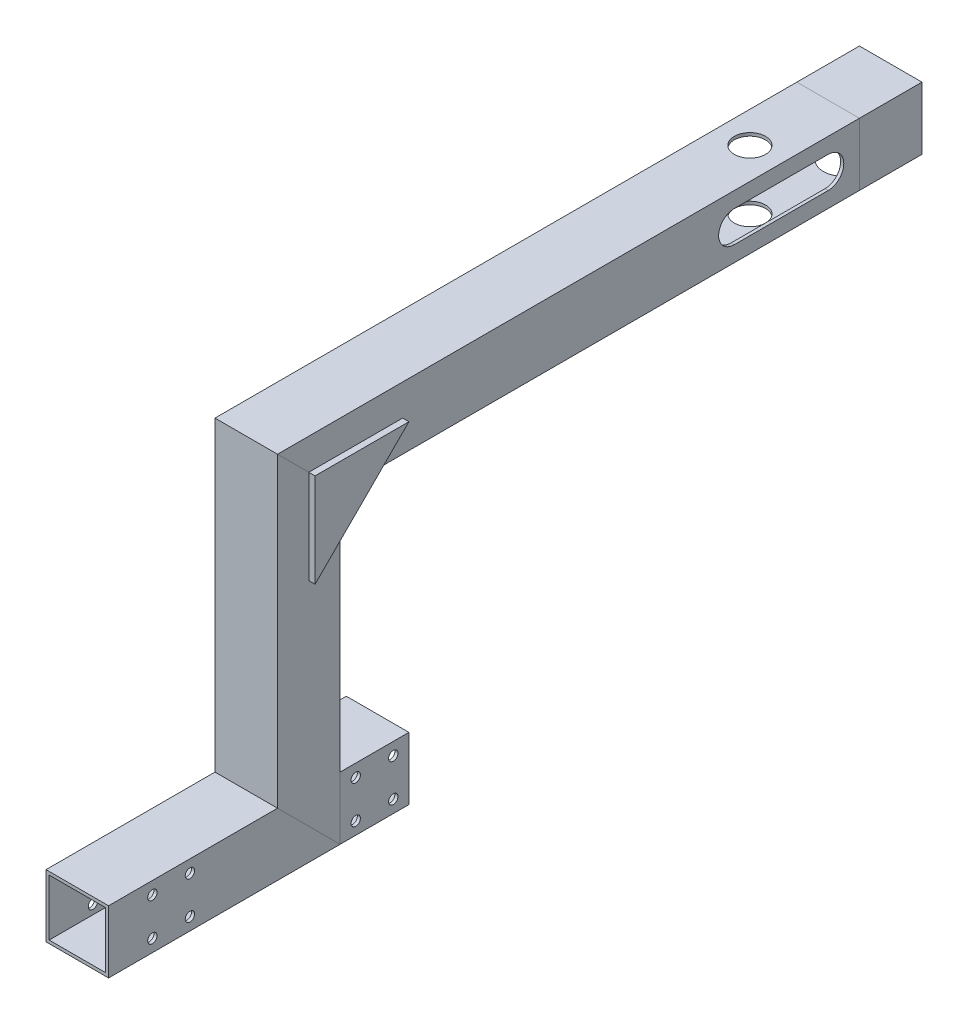
from build123d import *

# Parameters (mm, degrees)
SKETCH_14_W                = 20
SKETCH_14_H                = 20
SKETCH_14_W_2              = 18
SKETCH_14_H_2              = 18
F_20X20X1_1_DEPTH          = 79.142135624
SKETCH_14_ON_SEGMENT_2_W   = 20
SKETCH_14_ON_SEGMENT_2_H   = 20
SKETCH_14_ON_SEGMENT_2_W_2 = 18
SKETCH_14_ON_SEGMENT_2_H_2 = 18
F_20X20X1_1_2_DEPTH        = 128.284271247
SKETCH_14_ON_SEGMENT_3_W   = 20
SKETCH_14_ON_SEGMENT_3_H   = 20
SKETCH_14_ON_SEGMENT_3_W_2 = 18
SKETCH_14_ON_SEGMENT_3_H_2 = 18
F_20X20X1_1_3_DEPTH        = 191.142135624
SKETCH_14_ON_SEGMENT_4_W   = 20
SKETCH_14_ON_SEGMENT_4_H   = 20
SKETCH_14_ON_SEGMENT_4_W_2 = 18
SKETCH_14_ON_SEGMENT_4_H_2 = 18
F_20X20X1_1_4_DEPTH        = 62
SKETCH_12_R                = 1.5
CUT_EXTRUDE_1_DEPTH        = 264.939386981
CUT_EXTRUDE_3_DEPTH        = 264.939386981
CUT_EXTRUDE_4_DEPTH        = 260.43014474
EXTRUDE_1_DEPTH            = 2
EXTRUDE_2_DEPTH            = 2
SKETCH_25_W                = 20
SKETCH_25_H                = 20
SKETCH_25_W_2              = 18
SKETCH_25_H_2              = 18
EXTRUDE_3_DEPTH            = 20
SKETCH_26_R                = 6.5
CUT_EXTRUDE_9_DEPTH        = 1
SKETCH_27_R                = 1.5
CUT_EXTRUDE_10_DEPTH       = 1
SKETCH_17_R                = 1.5
CUT_EXTRUDE_11_DEPTH       = 283.396883835
SKETCH_28_W                = 29
SKETCH_28_H                = 20
CUT_EXTRUDE_12_DEPTH       = 283.396883835


with BuildPart() as part:
    # 草图14 → 铝管 20X20X1(1) (new body)
    with BuildSketch(Plane.YX):
        Rectangle(SKETCH_14_W, SKETCH_14_H)
        Rectangle(SKETCH_14_W_2, SKETCH_14_H_2, mode=Mode.SUBTRACT)
    extrude(amount=F_20X20X1_1_DEPTH)

    # 铝管 20X20X1(1) mitre 1
    split(bisect_by=Plane(origin=(0, 0, -64), x_dir=(1, 0, 0), z_dir=(0, -0.707106781, 0.707106781)), keep=Keep.TOP)

    # 草图12 → 切除-拉伸1 (cut, through all)
    with BuildSketch(Plane(origin=(10, 0, 0), x_dir=(0, 0, -1), z_dir=(1, 0, 0))):
        with Locations((14, 6)):
            Circle(SKETCH_12_R)
        with Locations((14, -6)):
            Circle(SKETCH_12_R)
        with Locations((26, -6)):
            Circle(SKETCH_12_R)
        with Locations((26, 6)):
            Circle(SKETCH_12_R)
    extrude(amount=-CUT_EXTRUDE_1_DEPTH, mode=Mode.SUBTRACT)


with BuildPart() as body_2:
    # 草图14 on segment 2 (carried to segment 2) → 20X20X1_1 2 (new body)
    with BuildSketch(Plane(origin=(0, -15.142135624, -64), x_dir=(0, 0, 1), z_dir=(0, 1, 0))):
        Rectangle(SKETCH_14_ON_SEGMENT_2_W, SKETCH_14_ON_SEGMENT_2_H)
        Rectangle(SKETCH_14_ON_SEGMENT_2_W_2, SKETCH_14_ON_SEGMENT_2_H_2, mode=Mode.SUBTRACT)
    extrude(amount=F_20X20X1_1_2_DEPTH)

    # 20X20X1_1 2 mitre 1
    split(bisect_by=Plane(origin=(0, 0, -64), x_dir=(-1, 0, 0), z_dir=(0, 0.707106781, -0.707106781)), keep=Keep.TOP)

    # 20X20X1_1 2 mitre 2
    split(bisect_by=Plane(origin=(0, 98, -64), x_dir=(1, 0, 0), z_dir=(0, -0.707106781, 0.707106781)), keep=Keep.TOP)


with BuildPart() as body_3:
    # 草图14 on segment 3 (carried to segment 3) → 20X20X1_1 3 (new body)
    with BuildSketch(Plane(origin=(0, 98, -48.857864376), x_dir=(0, 1, 0), z_dir=(0, 0, -1))):
        Rectangle(SKETCH_14_ON_SEGMENT_3_W, SKETCH_14_ON_SEGMENT_3_H)
        Rectangle(SKETCH_14_ON_SEGMENT_3_W_2, SKETCH_14_ON_SEGMENT_3_H_2, mode=Mode.SUBTRACT)
    extrude(amount=F_20X20X1_1_3_DEPTH)

    # 20X20X1_1 3 mitre 1
    split(bisect_by=Plane(origin=(0, 98, -64), x_dir=(-1, 0, 0), z_dir=(0, 0.707106781, -0.707106781)), keep=Keep.TOP)

    # 草图15 → 切除-拉伸3 (cut, through all)
    with BuildSketch(Plane(origin=(10, 0, 0), x_dir=(0, 0, -1), z_dir=(1, 0, 0))):
        with BuildLine():
            Line((200, 103), (230, 103))
            ThreePointArc((230, 103), (235, 98), (230, 93))
            Line((230, 93), (200, 93))
            ThreePointArc((200, 93), (195, 98), (200, 103))
        make_face()
    extrude(amount=-CUT_EXTRUDE_3_DEPTH, mode=Mode.SUBTRACT)

    # 草图16 → 切除-拉伸4 (cut, through all)
    with BuildSketch(Plane.XZ.offset(-88)):
        with BuildLine():
            ThreePointArc((-5, -215), (0, -220), (5, -215))
            Line((5, -215), (-5, -215))
        make_face()
        with BuildLine():
            Line((-5, -215), (5, -215))
            ThreePointArc((5, -215), (0, -210), (-5, -215))
        make_face()
    extrude(amount=-CUT_EXTRUDE_4_DEPTH, mode=Mode.SUBTRACT)


with BuildPart() as body_4:
    # 草图14 on segment 4 (carried to segment 4) → 20X20X1_1 4 (new body)
    with BuildSketch(Plane.YX.offset(63)):
        Rectangle(SKETCH_14_ON_SEGMENT_4_W, SKETCH_14_ON_SEGMENT_4_H)
        Rectangle(SKETCH_14_ON_SEGMENT_4_W_2, SKETCH_14_ON_SEGMENT_4_H_2, mode=Mode.SUBTRACT)
    extrude(amount=F_20X20X1_1_4_DEPTH)

    # 20X20X1_1 4 mitre 1
    split(bisect_by=Plane.YX.offset(74), keep=Keep.TOP)

    # 草图17 → 切除-拉伸11 (cut, through all)
    with BuildSketch(Plane(origin=(10, 0, 0), x_dir=(0, 0, -1), z_dir=(1, 0, 0))):
        with Locations((79, 6)):
            Circle(SKETCH_17_R)
        with Locations((79, -6)):
            Circle(SKETCH_17_R)
        with Locations((91, -6)):
            Circle(SKETCH_17_R)
        with Locations((91, 6)):
            Circle(SKETCH_17_R)
    extrude(amount=-CUT_EXTRUDE_11_DEPTH, mode=Mode.SUBTRACT)

    # 草图28 → 切除-拉伸12 (cut, through all)
    with BuildSketch(Plane(origin=(10, 0, 0), x_dir=(0, 0, -1), z_dir=(1, 0, 0))):
        with Locations((110.5, 0)):
            Rectangle(SKETCH_28_W, SKETCH_28_H)
    extrude(amount=-CUT_EXTRUDE_12_DEPTH, mode=Mode.SUBTRACT)


with BuildPart() as body_5:
    # 草图22 → 凸台-拉伸1 (new body)
    with BuildSketch(Plane(origin=(10, 0, 0), x_dir=(0, 0, -1), z_dir=(1, 0, 0))):
        Polygon((64, 98), (64, 68), (94, 98), align=None)
    extrude(amount=EXTRUDE_1_DEPTH)


with BuildPart() as body_6:
    # 草图23 → 凸台-拉伸2 (new body)
    with BuildSketch(Plane.ZY.offset(10)):
        Polygon((-64, 98), (-94, 98), (-64, 68), align=None)
    extrude(amount=EXTRUDE_2_DEPTH)


with BuildPart() as body_7:
    # 草图25 → 凸台-拉伸3 (new body)
    with BuildSketch(Plane(origin=(0, 0, -240), x_dir=(-1, 0, 0), z_dir=(0, 0, -1))):
        with Locations((0, 98)):
            Rectangle(SKETCH_25_W, SKETCH_25_H)
        with Locations((0, 98)):
            Rectangle(SKETCH_25_W_2, SKETCH_25_H_2, mode=Mode.SUBTRACT)
    extrude(amount=EXTRUDE_3_DEPTH)


with BuildPart() as cut_extrude_9_tool:
    # 草图26 → 切除-拉伸9 (new body)
    with BuildSketch(Plane(origin=(0, 88, 0), x_dir=(1, 0, 0), z_dir=(0, 1, 0))):
        with Locations((0, 245)):
            Circle(SKETCH_26_R)
    extrude(amount=CUT_EXTRUDE_9_DEPTH)


with BuildPart() as body_3_1:
    add(body_3.part)

    # 切除-拉伸9: cut by cut_extrude_9_tool
    add(cut_extrude_9_tool.part, mode=Mode.SUBTRACT)


with BuildPart() as body_7_1:
    add(body_7.part)

    # 切除-拉伸9: cut by cut_extrude_9_tool
    add(cut_extrude_9_tool.part, mode=Mode.SUBTRACT)

    # 草图27 → 切除-拉伸10 (cut)
    with BuildSketch(Plane.XZ.offset(-88)):
        with Locations(Location((6, -254, 0), (0, 0, 270))):
            Circle(SKETCH_27_R)
    extrude(amount=-CUT_EXTRUDE_10_DEPTH, mode=Mode.SUBTRACT)


solid = Compound([part.part, body_2.part, body_4.part, body_5.part, body_6.part, body_3_1.part, body_7_1.part])
